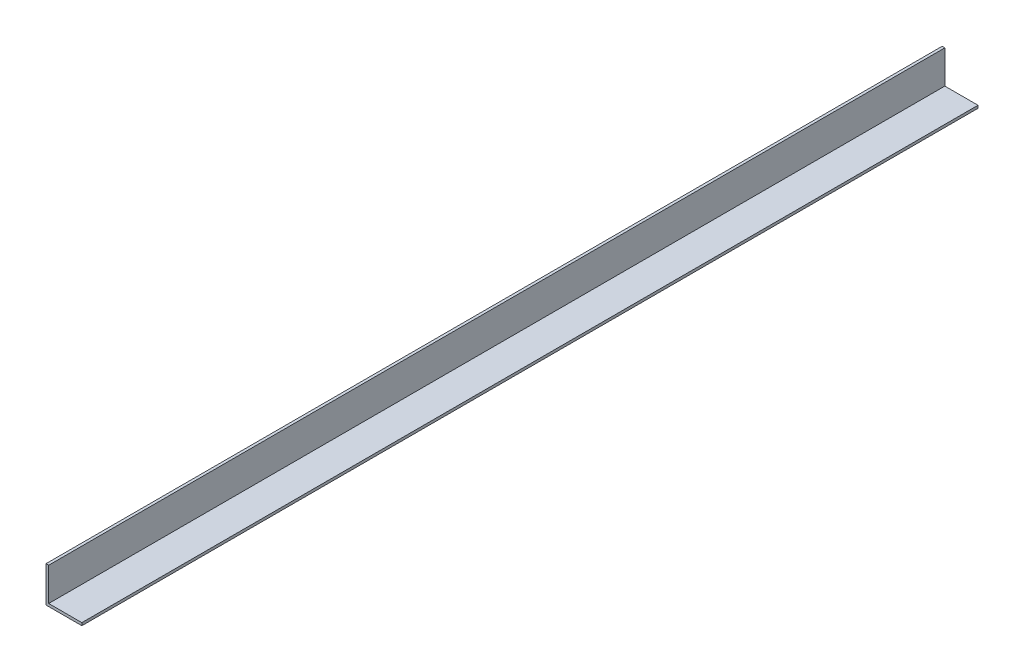
from build123d import *

# Parameters (mm, degrees)
EXTRUDE_1_DEPTH = 1000


with BuildPart() as part:
    # Эскиз1 → Бобышка-Вытянуть1 (new body)
    with BuildSketch(Plane.XY):
        Polygon((0, 40), (0, 0), (40, 0), (40, 3), (3, 3), (3, 40), align=None)
    extrude(amount=EXTRUDE_1_DEPTH)


solid = part.part
